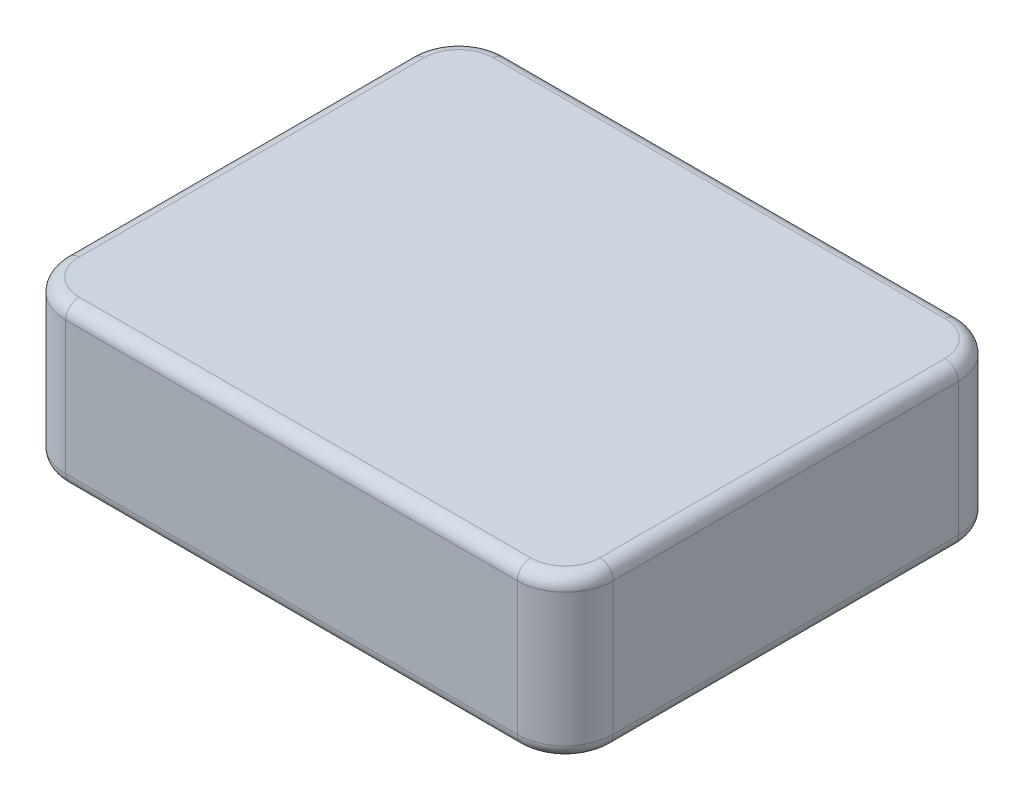
from build123d import *

# Parameters (mm, degrees)
BOSS_EXTRUDE1_DEPTH = 6
FILLET1_R           = 1


with BuildPart() as part:
    # Sketch1 → Boss-Extrude1 (new body, symmetric)
    with BuildSketch(Plane(origin=(0, 0, 0), x_dir=(1, 0, 0), z_dir=(0, 1, 0))):
        with BuildLine():
            Line((-16.965, -16.565), (16.965, -16.565))
            ThreePointArc((16.965, -16.565), (19.510584412, -15.510584412), (20.565, -12.965))
            Line((20.565, -12.965), (20.565, 12.965))
            ThreePointArc((20.565, 12.965), (19.510584412, 15.510584412), (16.965, 16.565))
            Line((16.965, 16.565), (-16.965, 16.565))
            ThreePointArc((-16.965, 16.565), (-19.510584412, 15.510584412), (-20.565, 12.965))
            Line((-20.565, 12.965), (-20.565, -12.965))
            ThreePointArc((-20.565, -12.965), (-19.510584412, -15.510584412), (-16.965, -16.565))
        make_face()
    extrude(amount=BOSS_EXTRUDE1_DEPTH, both=True)

    # Fillet1
    fillet1_edges = [part.edges().sort_by_distance(p)[0] for p in [
        (0, -6, -16.565),
        (19.510584412, -6, -15.510584412),
        (20.565, -6, 0),
        (19.510584412, -6, 15.510584412),
        (19.510584412, 6, -15.510584412),
        (0, 6, -16.565),
        (-19.510584412, 6, -15.510584412),
        (-20.565, 6, 0),
        (-19.510584412, 6, 15.510584412),
        (0, 6, 16.565),
        (19.510584412, 6, 15.510584412),
        (0, -6, 16.565),
        (20.565, 6, 0),
        (-19.510584412, -6, 15.510584412),
        (-20.565, -6, 0),
        (-19.510584412, -6, -15.510584412),
    ]]
    fillet(fillet1_edges, radius=FILLET1_R)


solid = part.part
